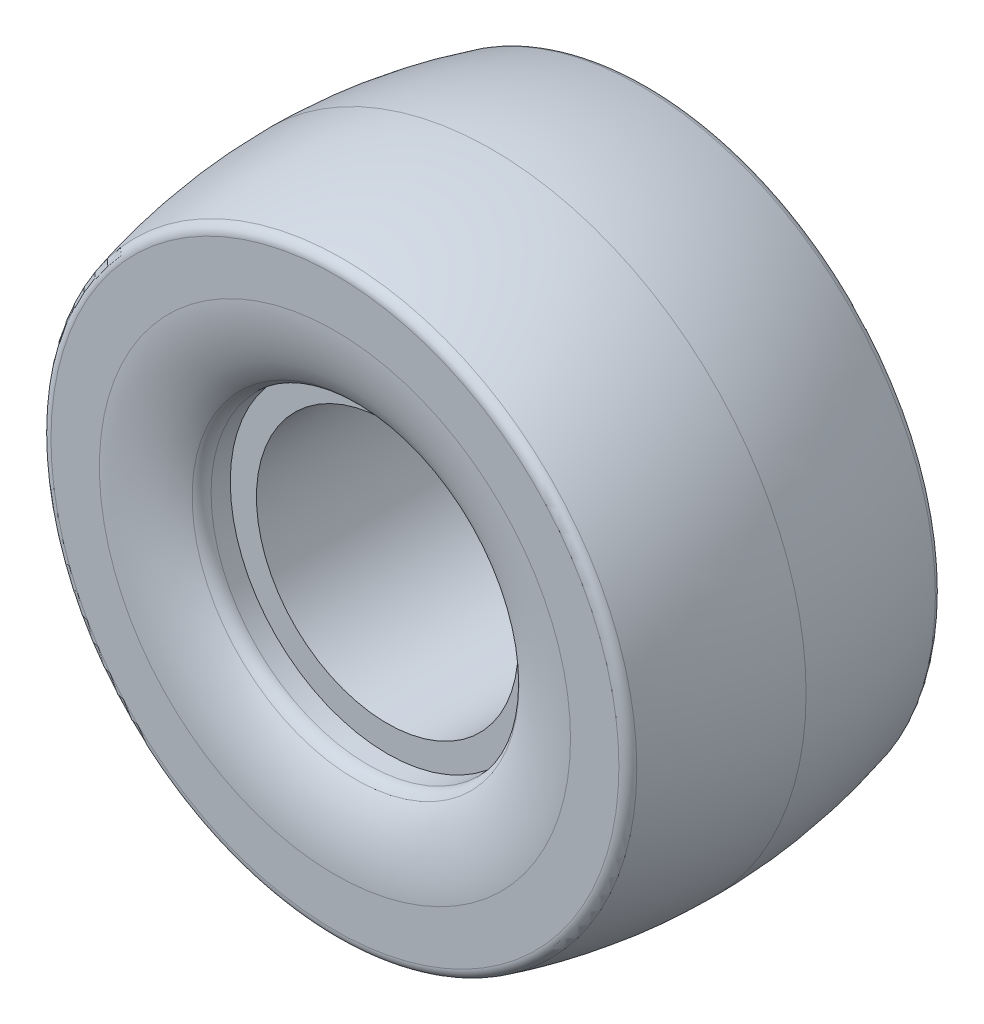
from build123d import *


with BuildPart() as part:
    # Sketch1 → Revolve1 (revolve)
    with BuildSketch(Plane(origin=(0, 0, 0), x_dir=(0, 0, -1), z_dir=(1, 0, 0))):
        with BuildLine():
            Line((20, 25), (-20, 25))
            Line((-20, 25), (-20, 30))
            Line((-20, 30), (-23.668508033, 30))
            ThreePointArc((-23.668508033, 30), (-25.014325105, 30.318810635), (-26.074101646, 31.207482393))
            add(Edge.make_bspline(
                [(-30, 45), (-30, 42.68615593), (-29.260358377, 37.431599739), (-27.2974092, 32.849185005), (-26.074101646, 31.207482393)],
                knots=[0, 0, 0, 0, 0.439021045, 0.878042089, 0.878042089, 0.878042089, 0.878042089], degree=3))
            Line((-30, 45), (-30, 54.245621199))
            ThreePointArc((-30, 54.245621199), (-29.586783181, 55.463044353), (-28.517880862, 56.177407784))
            add(Edge.make_bspline(
                [(-28.517880862, 56.177407784), (-23.764900718, 57.45160519), (-14.258940431, 59.362901297), (-4.752980144, 60), (0, 60)],
                knots=[0.024701986, 0.024701986, 0.024701986, 0.024701986, 0.262350993, 0.5, 0.5, 0.5, 0.5], degree=3))
            add(Edge.make_bspline(
                [(28.517880862, 56.177407784), (23.764900718, 57.45160519), (14.258940431, 59.362901297), (4.752980144, 60), (0, 60)],
                knots=[0.024701986, 0.024701986, 0.024701986, 0.024701986, 0.262350993, 0.5, 0.5, 0.5, 0.5], degree=3))
            ThreePointArc((28.517880862, 56.177407784), (29.586783181, 55.463044353), (30, 54.245621199))
            Line((30, 54.245621199), (30, 45))
            add(Edge.make_bspline(
                [(30, 45), (30, 42.68615593), (29.260358377, 37.431599739), (27.2974092, 32.849185005), (26.074101646, 31.207482393)],
                knots=[0, 0, 0, 0, 0.439021045, 0.878042089, 0.878042089, 0.878042089, 0.878042089], degree=3))
            ThreePointArc((26.074101646, 31.207482393), (25.014325105, 30.318810635), (23.668508033, 30))
            Line((23.668508033, 30), (20, 30))
            Line((20, 30), (20, 25))
        make_face()
    revolve(axis=Axis((0, 0, 30), (0, 0, -1)))


solid = part.part
